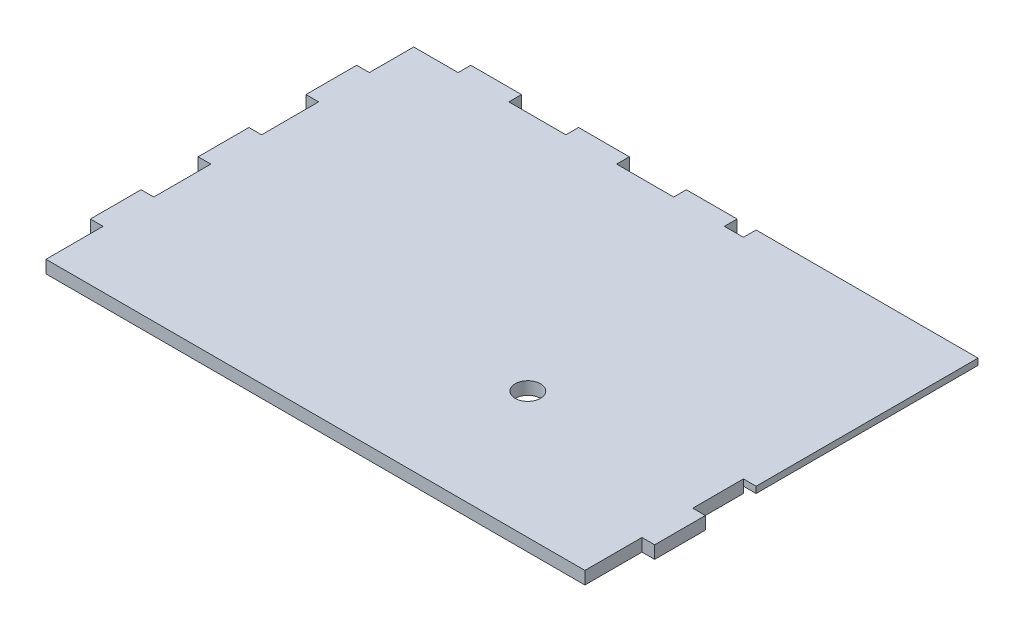
from build123d import *

# Parameters (mm, degrees)
SKETCH_370_W           = 89
SKETCH_370_H           = 60
EXTRUDE_438_DEPTH      = 2
CUT_EXTRUDE_684_DEPTH  = 2
SKETCH_734_W           = 2
SKETCH_734_H           = 25
CUT_EXTRUDE_885_DEPTH  = 2
SKETCH_933_W           = 8
SKETCH_933_H           = 2
EXTRUDE_1139_DEPTH     = 2
SKETCH_1188_W          = 8
SKETCH_1188_H          = 2
EXTRUDE_1389_DEPTH     = 2
SKETCH_1437_W          = 8
SKETCH_1437_H          = 2
EXTRUDE_1598_DEPTH     = 2
CUT_EXTRUDE_2168_DEPTH = 1
SKETCH_2222_R          = 2
CUT_EXTRUDE_2716_DEPTH = 3


with BuildPart() as part:
    # Sketch 370 → Extrude 438 (new body)
    with BuildSketch(Plane(origin=(0, 0, 0), x_dir=(1, 0, 0), z_dir=(0, 1, 0))):
        Rectangle(SKETCH_370_W, SKETCH_370_H)
    extrude(amount=EXTRUDE_438_DEPTH)

    # Sketch 488 → Cut-Extrude 684 (cut)
    with BuildSketch(Plane(origin=(0, 2, 0), x_dir=(1, 0, 0), z_dir=(0, 1, 0))):
        Polygon((-44.5, -30), (-42.5, -30), (-42.5, 28), (9.5, 28), (9.5, 30), (-44.5, 30), align=None)
    extrude(amount=-CUT_EXTRUDE_684_DEPTH, mode=Mode.SUBTRACT)

    # Sketch 734 → Cut-Extrude 885 (cut)
    with BuildSketch(Plane(origin=(0, 2, 0), x_dir=(1, 0, 0), z_dir=(0, 1, 0))):
        with Locations((43.5, -17.5)):
            Rectangle(SKETCH_734_W, SKETCH_734_H)
    extrude(amount=-CUT_EXTRUDE_885_DEPTH, mode=Mode.SUBTRACT)

    # Sketch 933 → Extrude 1139 (add)
    with BuildSketch(Plane.ZY.offset(42.5)):
        with Locations((17, 1)):
            Rectangle(SKETCH_933_W, SKETCH_933_H)
        with Locations((0, 1)):
            Rectangle(SKETCH_933_W, SKETCH_933_H)
        with Locations((-17, 1)):
            Rectangle(SKETCH_933_W, SKETCH_933_H)
    extrude(amount=EXTRUDE_1139_DEPTH)

    # Sketch 1188 → Extrude 1389 (add)
    with BuildSketch(Plane(origin=(0, 0, -28), x_dir=(-1, 0, 0), z_dir=(0, 0, -1))):
        with Locations((31.5, 1)):
            Rectangle(SKETCH_1188_W, SKETCH_1188_H)
        with Locations((14.5, 1)):
            Rectangle(SKETCH_1188_W, SKETCH_1188_H)
        with Locations((-2.5, 1)):
            Rectangle(SKETCH_1188_W, SKETCH_1188_H)
    extrude(amount=EXTRUDE_1389_DEPTH)

    # Sketch 1437 → Extrude 1598 (add)
    with BuildSketch(Plane(origin=(42.5, 0, 0), x_dir=(0, 0, -1), z_dir=(1, 0, 0))):
        with Locations((-17, 1)):
            Rectangle(SKETCH_1437_W, SKETCH_1437_H)
    extrude(amount=EXTRUDE_1598_DEPTH)

    # Sketch 1650 → Cut-Extrude 2168 (cut)
    with BuildSketch(Plane.XZ):
        Polygon((44.5, -30), (9.5, -30), (9.5, -23), (37.5, 5), (44.5, 5), align=None)
    extrude(amount=-CUT_EXTRUDE_2168_DEPTH, mode=Mode.SUBTRACT)

    # Sketch 2222 → Cut-Extrude 2716 (cut, through all)
    with BuildSketch(Plane(origin=(0, 2, 0), x_dir=(1, 0, 0), z_dir=(0, 1, 0))):
        with Locations((13.5, -10)):
            Circle(SKETCH_2222_R)
    extrude(amount=-CUT_EXTRUDE_2716_DEPTH, mode=Mode.SUBTRACT)


solid = part.part
